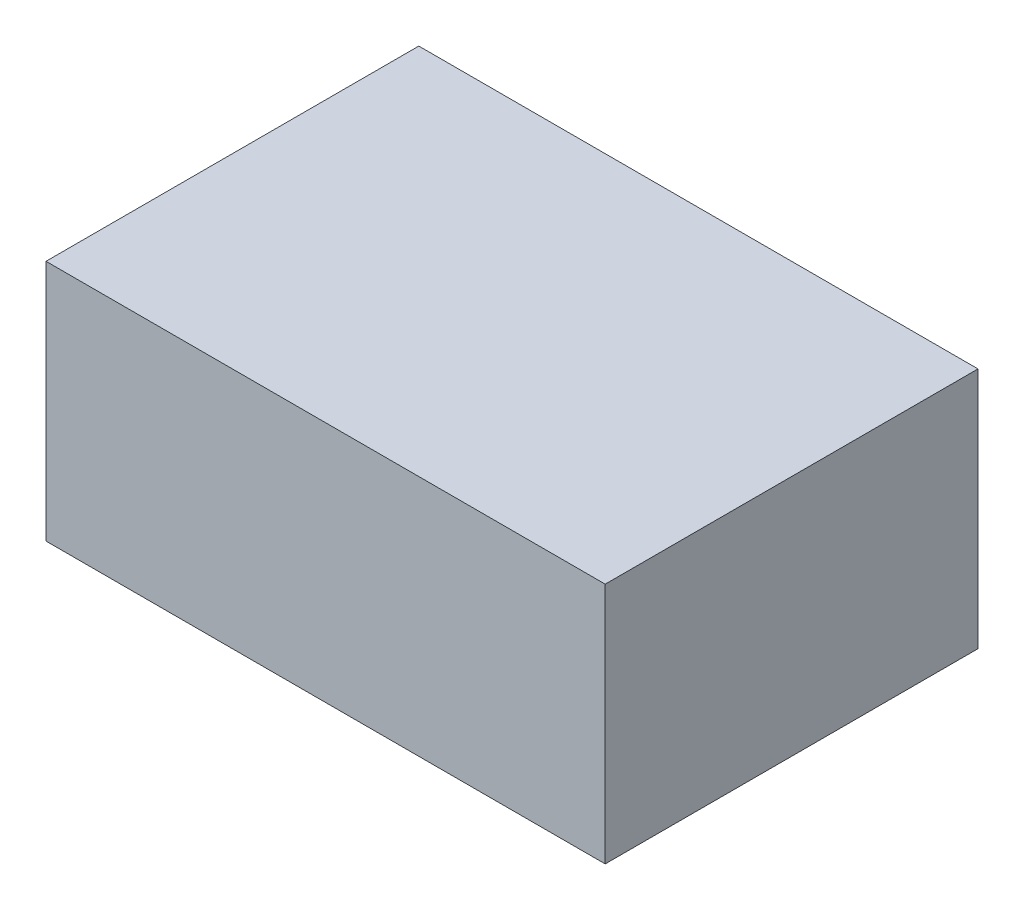
from build123d import *

# Parameters (mm, degrees)
SKETCH1_W           = 300
SKETCH1_H           = 200
BOSS_EXTRUDE1_DEPTH = 130


with BuildPart() as part:
    # Sketch1 → Boss-Extrude1 (new body)
    with BuildSketch(Plane(origin=(0, 0, 0), x_dir=(1, 0, 0), z_dir=(0, 1, 0))):
        with Locations((-79.133858268, 72.440944882)):
            Rectangle(SKETCH1_W, SKETCH1_H)
    extrude(amount=BOSS_EXTRUDE1_DEPTH)


solid = part.part
